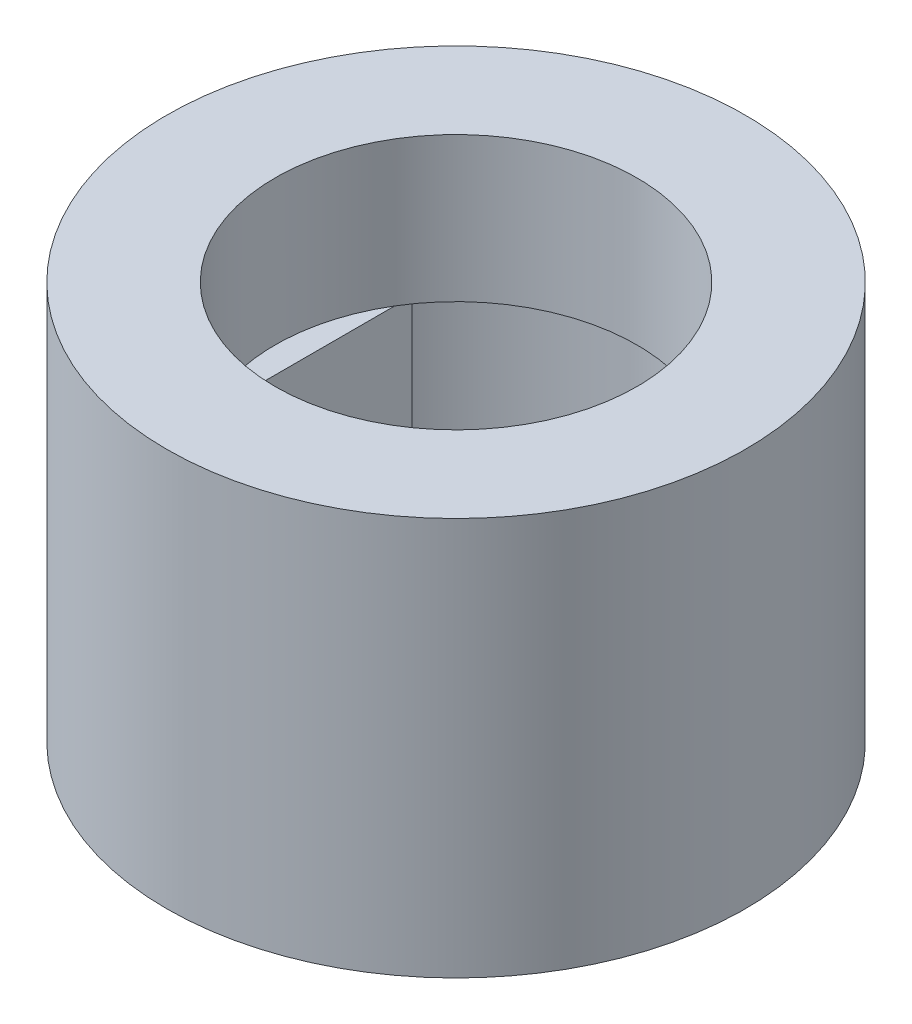
from build123d import *

# Parameters (mm, degrees)
SKETCH1_R           = 5.08
BOSS_EXTRUDE1_DEPTH = 6.985
CUT_EXTRUDE1_DEPTH  = 4.445
SKETCH3_R           = 3.175
CUT_EXTRUDE2_DEPTH  = 2.54


with BuildPart() as part:
    # Sketch1 → Boss-Extrude1 (new body)
    with BuildSketch(Plane(origin=(0, 0, 0), x_dir=(1, 0, 0), z_dir=(0, 1, 0))):
        Circle(SKETCH1_R)
    extrude(amount=BOSS_EXTRUDE1_DEPTH)

    # Sketch2 → Cut-Extrude1 (cut)
    with BuildSketch(Plane(origin=(0, 0, 0), x_dir=(1, 0, 0), z_dir=(0, 1, 0))):
        with BuildLine():
            Line((-2.7178, 1.941605307), (-2.7178, -1.941605307))
            ThreePointArc((-2.7178, -1.941605307), (1.019446965, -3.180722543), (3.3401, 0))
            ThreePointArc((3.3401, 0), (1.019446965, 3.180722543), (-2.7178, 1.941605307))
        make_face()
    extrude(amount=CUT_EXTRUDE1_DEPTH, mode=Mode.SUBTRACT)

    # Sketch3 → Cut-Extrude2 (cut)
    with BuildSketch(Plane(origin=(0, 6.985, 0), x_dir=(1, 0, 0), z_dir=(0, 1, 0))):
        Circle(SKETCH3_R)
    extrude(amount=-CUT_EXTRUDE2_DEPTH, mode=Mode.SUBTRACT)


solid = part.part
